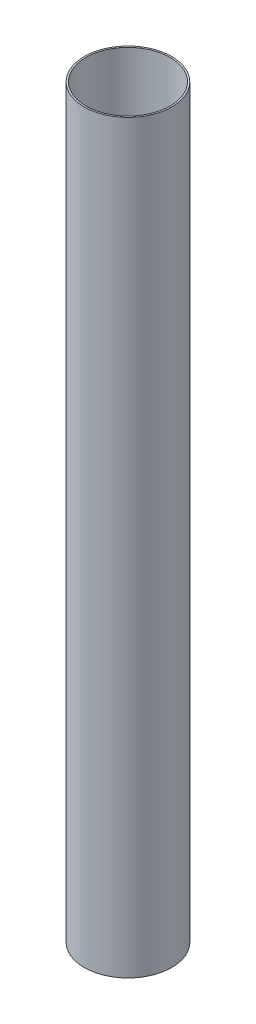
from build123d import *

# Parameters (mm, degrees)
SKETCH1_R           = 27
BOSS_EXTRUDE1_DEPTH = 460
SHELL1_T            = -1


with BuildPart() as part:
    # Sketch1 → Boss-Extrude1 (new body)
    with BuildSketch(Plane(origin=(0, 0, 0), x_dir=(1, 0, 0), z_dir=(0, 1, 0))):
        with Locations(Location((0, 0, 0), (0, 0, 270))):
            Circle(SKETCH1_R)
    extrude(amount=BOSS_EXTRUDE1_DEPTH)

    # Shell1
    shell1_openings = [part.faces().sort_by_distance(p)[0] for p in [
        (0, 460, 0),
        (0, 0, 0),
    ]]
    offset(amount=SHELL1_T, openings=shell1_openings, kind=Kind.INTERSECTION)


solid = part.part
